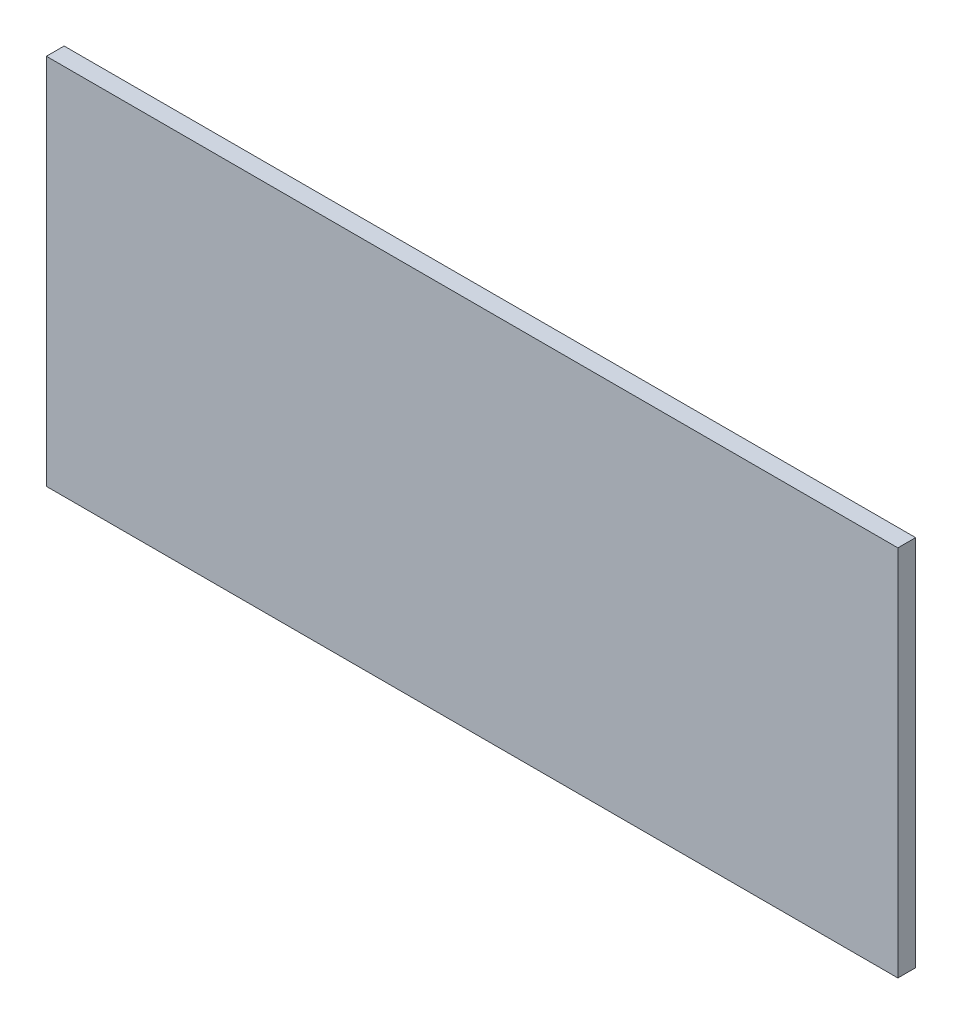
from build123d import *

# Parameters (mm, degrees)
ESQUISSE1_W        = 480
ESQUISSE1_H        = 210
BOSS_EXTRU_1_DEPTH = 10


with BuildPart() as part:
    # Esquisse1 → Boss.-Extru.1 (new body)
    with BuildSketch(Plane.XY):
        with Locations((-50, 0)):
            Rectangle(ESQUISSE1_W, ESQUISSE1_H)
    extrude(amount=BOSS_EXTRU_1_DEPTH)


solid = part.part
